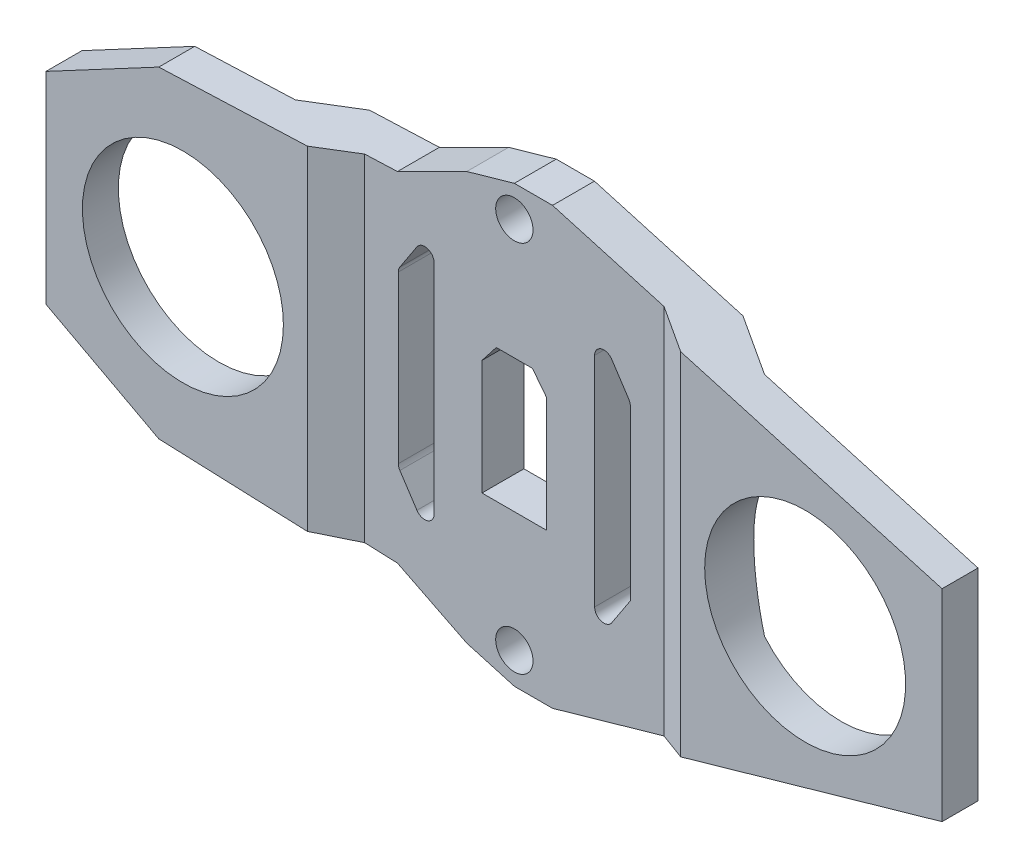
from build123d import *

# Parameters (mm, degrees)
SKETCH1_R               = 3
SKETCH1_R_2             = 16.15
BOSS_EXTRUDE1_DEPTH     = 10
CUT_EXTRUDE1_DEPTH      = 36
CUT_EXTRUDE1_DEPTH_BACK = 36
CUT_EXTRUDE2_DEPTH      = 4.263908078
CUT_EXTRUDE2_DEPTH_BACK = 7.736091922
CUT_EXTRUDE3_DEPTH      = 4.263908078
CUT_EXTRUDE3_DEPTH_BACK = 7.736091922
FILLET1_R               = 1.5


with BuildPart() as part:
    # Sketch1 → Boss-Extrude1 (new body)
    with BuildSketch(Plane.XY):
        Polygon((-72, 16.21061599), (-72, -16.21061599), (-53.874481608, -25.873120341), (-18.780890439, -27.25079114), (-7.646290238, -32.818629475), (0, -35), (6.138156767, -35), (72, -16.21061599), (72, 16.21061599), (6.138156767, 35), (0, 35), (-7.646290238, 32.818629475), (-18.780890439, 27.25079114), (-53.874481608, 25.873120341), align=None)
        with Locations((0, 30)):
            Circle(SKETCH1_R, mode=Mode.SUBTRACT)
        with Locations((-50, 0)):
            Circle(SKETCH1_R_2, mode=Mode.SUBTRACT)
        with Locations((0, -30)):
            Circle(SKETCH1_R, mode=Mode.SUBTRACT)
        with Locations((50, 0)):
            Circle(SKETCH1_R_2, mode=Mode.SUBTRACT)
    extrude(amount=BOSS_EXTRUDE1_DEPTH)

    # Sketch2 → Cut-Extrude1 (cut, two sides)
    with BuildSketch(Plane(origin=(0, 0, 0), x_dir=(1, 0, 0), z_dir=(0, 1, 0))) as cut_extrude1_sk:
        Polygon((-30, -10), (-24.053688771, -6.736091922), (4.484766303, -6.736091922), (24.053688771, -6.736091922), (30, -10), align=None)
        Polygon((-72, 0), (-72, -4.2256576), (-37.698462898, -4.2256576), (-30, 0), align=None)
        Polygon((30, 0), (72, 0), (72, -4.2256576), (37.698462898, -4.2256576), align=None)
    extrude(amount=CUT_EXTRUDE1_DEPTH, mode=Mode.SUBTRACT)
    extrude(cut_extrude1_sk.sketch, amount=-CUT_EXTRUDE1_DEPTH_BACK, mode=Mode.SUBTRACT)

    # Sketch3 → Cut-Extrude2 (cut, two sides)
    with BuildSketch(Plane.XY.offset(6.736091922)) as cut_extrude2_sk:
        Polygon((5.2, -10.7), (-5.2, -10.7), (-5.2, 7.758003241), (-2.908652734, 10.7), (2.908652734, 10.7), (5.2, 7.758003241), align=None)
    extrude(amount=CUT_EXTRUDE2_DEPTH, mode=Mode.SUBTRACT)
    extrude(cut_extrude2_sk.sketch, amount=-CUT_EXTRUDE2_DEPTH_BACK, mode=Mode.SUBTRACT)

    # Sketch4 → Cut-Extrude3 (cut, two sides)
    with BuildSketch(Plane.XY.offset(6.736091922)) as cut_extrude3_sk:
        Polygon((-18.641801382, 13.783435693), (-18.641801382, -13.783435693), (-12.900018937, -22.526604416), (-12.900018937, 22.526604416), align=None)
        Polygon((18.641801382, 13.783435693), (12.900018937, 22.526604416), (12.900018937, -22.526604416), (18.641801382, -13.783435693), align=None)
    extrude(amount=CUT_EXTRUDE3_DEPTH, mode=Mode.SUBTRACT)
    extrude(cut_extrude3_sk.sketch, amount=-CUT_EXTRUDE3_DEPTH_BACK, mode=Mode.SUBTRACT)

    # Fillet1
    fillet1_edges = [part.edges().sort_by_distance(p)[0] for p in [
        (-12.900018937, -22.526604416, 3.368045961),
        (-18.641801382, -13.783435693, 3.368045961),
        (-18.641801382, 13.783435693, 3.368045961),
        (-12.900018937, 22.526604416, 3.368045961),
        (18.641801382, 13.783435693, 3.368045961),
        (12.900018937, -22.526604416, 3.368045961),
        (12.900018937, 22.526604416, 3.368045961),
    ]]
    fillet(fillet1_edges, radius=FILLET1_R)


solid = part.part
